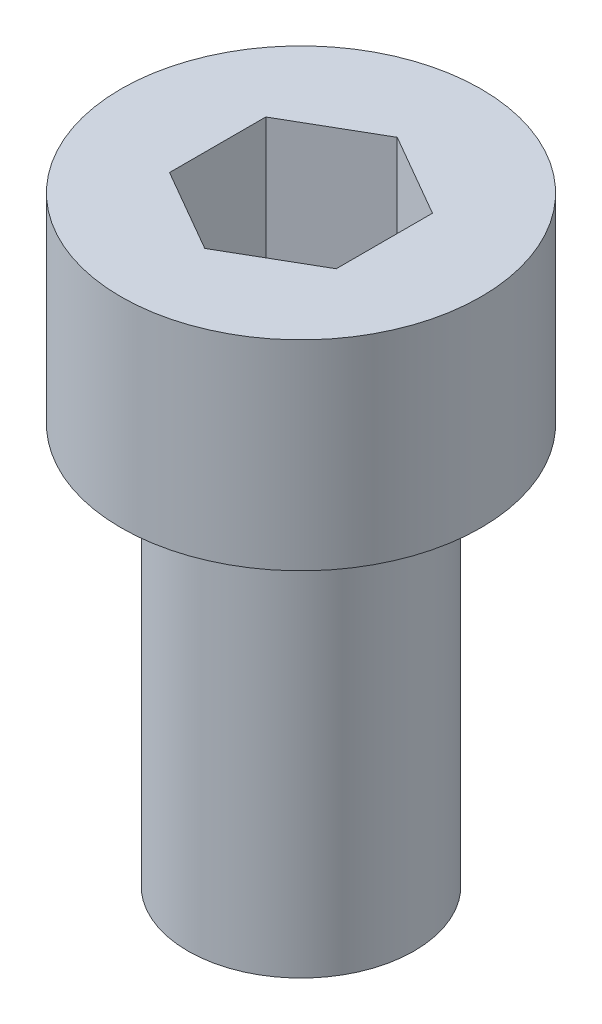
from build123d import *

# Parameters (mm, degrees)
SKETCH1_R           = 2.7
BOSS_EXTRUDE1_DEPTH = 3
SKETCH2_R           = 1.696293742
BOSS_EXTRUDE2_DEPTH = 6
CUT_EXTRUDE1_DEPTH  = 2


with BuildPart() as part:
    # Sketch1 → Boss-Extrude1 (new body)
    with BuildSketch(Plane(origin=(0, 0, 0), x_dir=(1, 0, 0), z_dir=(0, 1, 0))):
        with Locations((184.714490272, -125.24429514)):
            Circle(SKETCH1_R)
    extrude(amount=-BOSS_EXTRUDE1_DEPTH)

    # Sketch2 → Boss-Extrude2 (add)
    with BuildSketch(Plane.XZ.offset(3)):
        with Locations((184.714490272, 125.24429514)):
            Circle(SKETCH2_R)
    extrude(amount=BOSS_EXTRUDE2_DEPTH)

    # Sketch3 → Cut-Extrude1 (cut)
    with BuildSketch(Plane(origin=(0, 0, 0), x_dir=(1, 0, 0), z_dir=(0, 1, 0))):
        Polygon((184.714490272, -123.800919467), (183.464490272, -124.522607304), (183.464490272, -125.965982977), (184.714490272, -126.687670813), (185.964490272, -125.965982977), (185.964490272, -124.522607304), align=None)
    extrude(amount=-CUT_EXTRUDE1_DEPTH, mode=Mode.SUBTRACT)


solid = part.part
